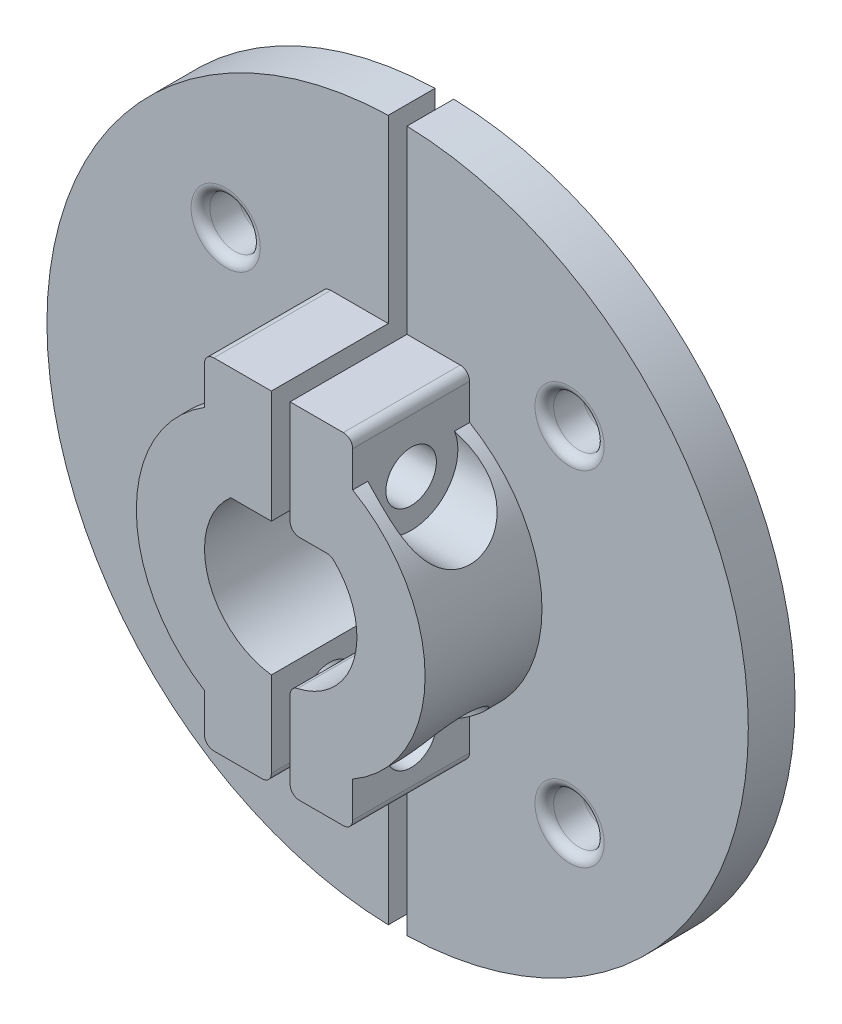
from build123d import *

# Parameters (mm, degrees)
SKETCH1_R                = 37.5
SKETCH1_R_2              = 8.15
SKETCH1_R_3              = 2.7
BOSS_EXTRUDE1_DEPTH      = 17.5
SKETCH2_OUTSIDE_W        = 98.5
SKETCH2_OUTSIDE_H        = 98.5
SKETCH2_OUTSIDE_R        = 15.44
CUT_EXTRUDE1_DEPTH       = 12.5
BOSS_EXTRUDE6_DEPTH      = 12.5
BOSS_EXTRUDE7_DEPTH      = 17.5
SKETCH15_W               = 2
SKETCH15_H               = 81.877927722
CUT_EXTRUDE9_DEPTH       = 1
CUT_EXTRUDE9_DEPTH_BACK  = 18.5
SKETCH16_R               = 2.7
CUT_EXTRUDE10_DEPTH      = 30.805442867
CUT_EXTRUDE10_DEPTH_BACK = 46.194557133
SKETCH17_R               = 5
CUT_EXTRUDE11_DEPTH      = 30.35
SKETCH19_R               = 5
CUT_EXTRUDE12_DEPTH      = 30.805442867
FILLET1_R                = 1
FILLET2_R                = 1


with BuildPart() as part:
    # Sketch1 → Boss-Extrude1 (new body)
    with BuildSketch(Plane.XY):
        Circle(SKETCH1_R)
        Circle(SKETCH1_R_2, mode=Mode.SUBTRACT)
        with Locations((18.384776311, 18.384776311)):
            Circle(SKETCH1_R_3, mode=Mode.SUBTRACT)
        with Locations((-18.384776311, 18.384776311)):
            Circle(SKETCH1_R_3, mode=Mode.SUBTRACT)
        with Locations((-18.384776311, -18.384776311)):
            Circle(SKETCH1_R_3, mode=Mode.SUBTRACT)
        with Locations((18.384776311, -18.384776311)):
            Circle(SKETCH1_R_3, mode=Mode.SUBTRACT)
    extrude(amount=BOSS_EXTRUDE1_DEPTH)

    # Sketch2 outside → Cut-Extrude1 (cut)
    with BuildSketch(Plane.XY.offset(17.5)):
        Rectangle(SKETCH2_OUTSIDE_W, SKETCH2_OUTSIDE_H)
        Circle(SKETCH2_OUTSIDE_R, mode=Mode.SUBTRACT)
    extrude(amount=-CUT_EXTRUDE1_DEPTH, mode=Mode.SUBTRACT)

    # Sketch5 → Boss-Extrude6 (add)
    with BuildSketch(Plane.XY.offset(5)):
        with BuildLine():
            Line((7.694557133, 13.386089441), (7.694557133, 18.20270779))
            Line((7.694557133, 18.20270779), (-8.15, 18.20270779))
            Line((-8.15, 18.20270779), (-8.15, 13.1137752))
            ThreePointArc((-8.15, 13.1137752), (-0.265322093, 15.437720175), (7.694557133, 13.386089441))
        make_face()
        with BuildLine():
            Line((7.694557133, -18.20270779), (7.694557133, -13.386089441))
            ThreePointArc((7.694557133, -13.386089441), (-0.265322093, -15.437720175), (-8.15, -13.1137752))
            Line((-8.15, -13.1137752), (-8.15, -18.20270779))
            Line((-8.15, -18.20270779), (7.694557133, -18.20270779))
        make_face()
    extrude(amount=BOSS_EXTRUDE6_DEPTH)

    # Sketch14 → Boss-Extrude7 (add)
    with BuildSketch(Plane(origin=(0, 0, 0), x_dir=(-1, 0, 0), z_dir=(0, 0, -1))):
        with BuildLine():
            Line((-5.347896783, 6.15), (0, 6.15))
            Line((0, 6.15), (5.347896783, 6.15))
            ThreePointArc((5.347896783, 6.15), (0, 8.15), (-5.347896783, 6.15))
        make_face()
    extrude(amount=-BOSS_EXTRUDE7_DEPTH)

    # Sketch15 → Cut-Extrude9 (cut, two sides)
    with BuildSketch(Plane.XY.offset(17.5)) as cut_extrude9_sk:
        Rectangle(SKETCH15_W, SKETCH15_H)
    extrude(amount=CUT_EXTRUDE9_DEPTH, mode=Mode.SUBTRACT)
    extrude(cut_extrude9_sk.sketch, amount=-CUT_EXTRUDE9_DEPTH_BACK, mode=Mode.SUBTRACT)

    # Sketch16 → Cut-Extrude10 (cut, two sides)
    with BuildSketch(Plane(origin=(7.694557133, 0, 0), x_dir=(0, 0, -1), z_dir=(1, 0, 0))) as cut_extrude10_sk:
        with Locations((-11.25, 11.512791967)):
            Circle(SKETCH16_R)
        with Locations((-11.25, -12.744602279)):
            Circle(SKETCH16_R)
    extrude(amount=CUT_EXTRUDE10_DEPTH, mode=Mode.SUBTRACT)
    extrude(cut_extrude10_sk.sketch, amount=-CUT_EXTRUDE10_DEPTH_BACK, mode=Mode.SUBTRACT)

    # Sketch17 → Cut-Extrude11 (cut, through all)
    with BuildSketch(Plane.ZY.offset(8.15)):
        with Locations((11.25, 11.512791967)):
            Circle(SKETCH17_R)
        with Locations((11.25, -12.744602279)):
            Circle(SKETCH17_R)
    extrude(amount=CUT_EXTRUDE11_DEPTH, mode=Mode.SUBTRACT)

    # Sketch19 → Cut-Extrude12 (cut, through all)
    with BuildSketch(Plane(origin=(7.694557133, 0, 0), x_dir=(0, 0, -1), z_dir=(1, 0, 0))):
        with Locations((-11.25, 11.512791967)):
            Circle(SKETCH19_R)
        with Locations((-11.25, -12.744602279)):
            Circle(SKETCH19_R)
    extrude(amount=CUT_EXTRUDE12_DEPTH, mode=Mode.SUBTRACT)

    # Fillet1
    fillet1_edges = [part.edges().sort_by_distance(p)[0] for p in [
        (1, -18.20270779, 11.25),
        (1, -8.088417645, 8.75),
        (15.684776311, -18.384776311, 0),
        (15.684776311, -18.384776311, 5),
        (15.684776311, 18.384776311, 5),
        (7.694557133, 18.20270779, 11.25),
        (7.694557133, -18.20270779, 11.25),
        (5.347896783, 6.15, 8.75),
        (15.684776311, 18.384776311, 0),
        (1, 6.15, 8.75),
    ]]
    fillet(fillet1_edges, radius=FILLET1_R)

    # Fillet2
    fillet2_edges = [part.edges().sort_by_distance(p)[0] for p in [
        (-21.084776311, -18.384776311, 0),
        (-21.084776311, 18.384776311, 0),
        (-1, -18.20270779, 11.25),
        (-8.15, -18.20270779, 11.25),
        (-21.084776311, 18.384776311, 5),
        (-21.084776311, -18.384776311, 5),
        (-8.15, 18.20270779, 11.25),
    ]]
    fillet(fillet2_edges, radius=FILLET2_R)


solid = part.part
